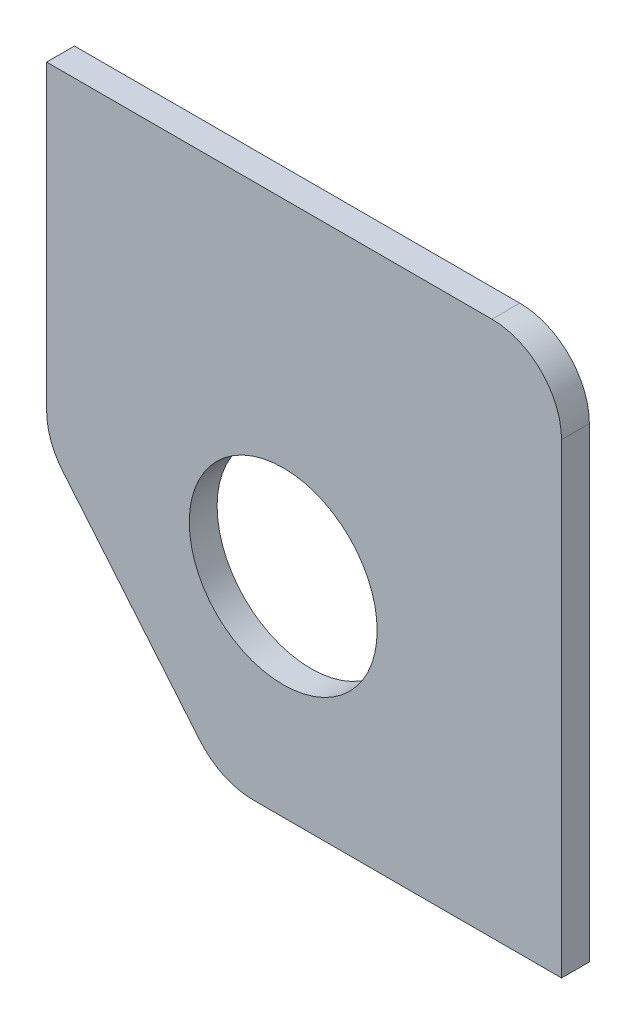
from build123d import *

# Parameters (mm, degrees)
ESBO_O1_W                  = 74
ESBO_O1_H                  = 77
RESSALTO_EXTRUS_O1_DEPTH   = 4
CORTE_EXTRUS_O1_DEPTH      = 4
CORTE_EXTRUS_O1_DEPTH_BACK = 4
ESBO_O2_R                  = 13.5
CORTE_EXTRUS_O2_DEPTH      = 97.844420883
CORTE_EXTRUS_O2_DEPTH_BACK = 97.844420883
FILETE2_R                  = 10
FILETE3_R                  = 10
FILETE4_R                  = 10


with BuildPart() as part:
    # Esboço1 → Ressalto-extrusão1 (new body)
    with BuildSketch(Plane.XY):
        with Locations((-49.165685596, 5.526315789)):
            Rectangle(ESBO_O1_W, ESBO_O1_H)
    extrude(amount=RESSALTO_EXTRUS_O1_DEPTH)

    # Esboço2 → Corte-extrusão1 (cut, two sides: drawn at the far end of the back side and taken through both)
    with BuildSketch(Plane.XY.offset(4).offset(-CORTE_EXTRUS_O1_DEPTH_BACK)):
        with Locations((-52.165685596, -2.973684211)):
            Circle(ESBO_O2_R)
    extrude(amount=CORTE_EXTRUS_O1_DEPTH + CORTE_EXTRUS_O1_DEPTH_BACK, mode=Mode.SUBTRACT)

    # Esboço4 → Corte-extrusão2 (cut, two sides: drawn at the far end of the back side and taken through both)
    with BuildSketch(Plane.XY.offset(4).offset(-CORTE_EXTRUS_O2_DEPTH_BACK)):
        Polygon((62.093925387, -180.88521739), (-61.165685596, -32.973684211), (-86.165685596, -2.973684211), (-209.425296578, 144.937848968), (-505.248362936, -101.581372997), (-233.729140971, -427.404439354), align=None)
    extrude(amount=CORTE_EXTRUS_O2_DEPTH + CORTE_EXTRUS_O2_DEPTH_BACK, mode=Mode.SUBTRACT)

    # Filete2
    filete2_edges = [part.edges().sort_by_distance(p)[0] for p in [
        (-86.165685596, -2.973684211, 2),
    ]]
    fillet(filete2_edges, radius=FILETE2_R)

    # Filete3
    filete3_edges = [part.edges().sort_by_distance(p)[0] for p in [
        (-61.165685596, -32.973684211, 2),
    ]]
    fillet(filete3_edges, radius=FILETE3_R)

    # Filete4
    filete4_edges = [part.edges().sort_by_distance(p)[0] for p in [
        (-12.165685596, 44.026315789, 2),
    ]]
    fillet(filete4_edges, radius=FILETE4_R)


solid = part.part
